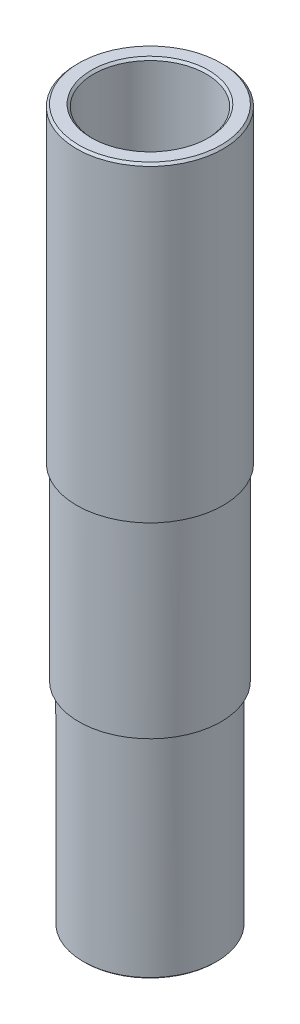
from build123d import *

# Parameters (mm, degrees)
SKETCH1_R           = 16
SKETCH1_R_2         = 12.7
BOSS_EXTRUDE1_DEPTH = 160
CHAMFER2_SIZE       = 0.3
SKETCH3_R           = 17.5
SKETCH3_R_2         = 15
CUT_EXTRUDE2_DEPTH  = 47.56
CHAMFER3_SIZE       = 0.3
SKETCH2_R           = 16.5
SKETCH2_R_2         = 12.7
BOSS_EXTRUDE3_DEPTH = 70
CHAMFER4_SIZE       = 0.5


with BuildPart() as part:
    # Sketch1 → Boss-Extrude1 (new body)
    with BuildSketch(Plane(origin=(0, 0, 0), x_dir=(1, 0, 0), z_dir=(0, 1, 0))):
        Circle(SKETCH1_R)
        Circle(SKETCH1_R_2, mode=Mode.SUBTRACT)
    extrude(amount=BOSS_EXTRUDE1_DEPTH)

    # Chamfer2
    chamfer2_edges = [part.edges().sort_by_distance(p)[0] for p in [
        (-12.7, 0, 0),
        (-12.7, 160, 0),
    ]]
    chamfer(chamfer2_edges, length=CHAMFER2_SIZE)

    # Sketch3 → Cut-Extrude2 (cut)
    with BuildSketch(Plane.XZ):
        Circle(SKETCH3_R)
        Circle(SKETCH3_R_2, mode=Mode.SUBTRACT)
    extrude(amount=-CUT_EXTRUDE2_DEPTH, mode=Mode.SUBTRACT)

    # Chamfer3
    chamfer3_edges = [part.edges().sort_by_distance(p)[0] for p in [
        (-15, 0, 0),
    ]]
    chamfer(chamfer3_edges, length=CHAMFER3_SIZE)

    # Sketch2 → Boss-Extrude3 (add)
    with BuildSketch(Plane(origin=(0, 160, 0), x_dir=(1, 0, 0), z_dir=(0, 1, 0))):
        Circle(SKETCH2_R)
        Circle(SKETCH2_R_2, mode=Mode.SUBTRACT)
    extrude(amount=-BOSS_EXTRUDE3_DEPTH)

    # Chamfer4
    chamfer4_edges = [part.edges().sort_by_distance(p)[0] for p in [
        (-16.5, 160, 0),
        (-12.7, 160, 0),
    ]]
    chamfer(chamfer4_edges, length=CHAMFER4_SIZE)


solid = part.part
